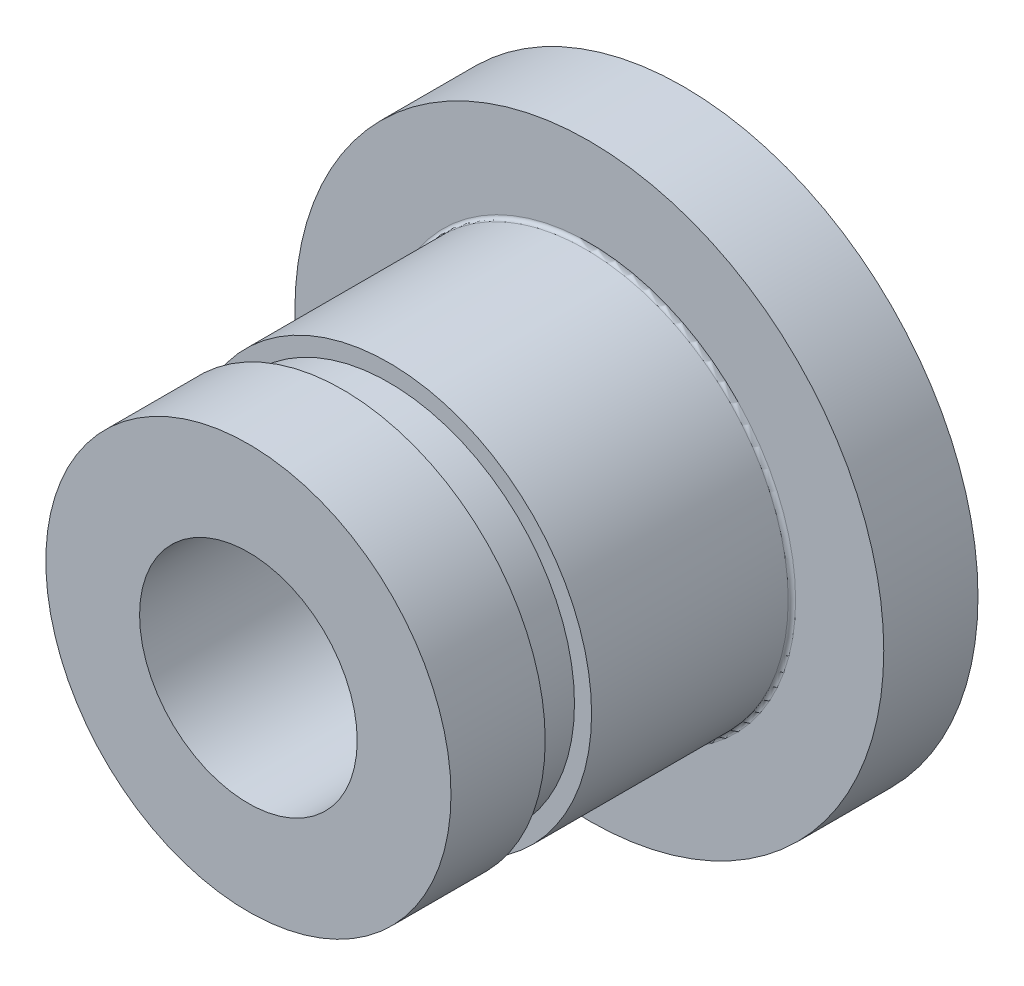
from build123d import *


with BuildPart() as part:
    # Sketch1 → Revolve1 (revolve)
    with BuildSketch(Plane(origin=(0, 0, 0), x_dir=(0, 0, -1), z_dir=(1, 0, 0))):
        with BuildLine():
            Line((0, 2.9337), (11.73, 2.9337))
            Line((11.73, 2.9337), (11.73, 7.9375))
            Line((11.73, 7.9375), (9.19, 7.9375))
            Line((9.19, 7.9375), (9.19, 5.561))
            ThreePointArc((9.19, 5.561), (9.160710678, 5.490289322), (9.09, 5.461))
            Line((9.09, 5.461), (3.79, 5.461))
            Line((3.79, 5.461), (3.79, 5))
            Line((3.79, 5), (2.54, 5))
            Line((2.54, 5), (2.54, 5.461))
            Line((2.54, 5.461), (0, 5.461))
            Line((0, 5.461), (0, 2.9337))
        make_face()
    revolve(axis=Axis((0, 0, 0), (0, 0, -1)))


solid = part.part
